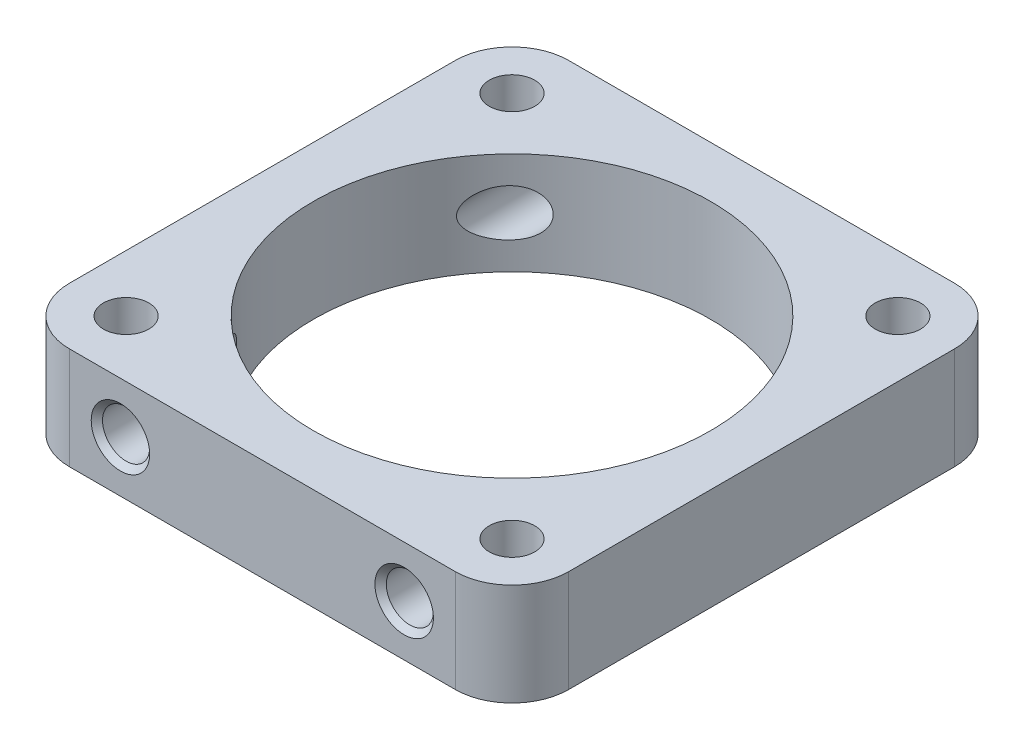
from build123d import *

# Parameters (mm, degrees)
SKETCH1_W           = 88
SKETCH1_H           = 88
BOSS_EXTRUDE1_DEPTH = 18
FILLET1_R           = 10
SKETCH2_R           = 2.15
CUT_EXTRUDE1_DEPTH  = 19
SKETCH3_R           = 4.15
CUT_EXTRUDE2_DEPTH  = 89
SKETCH4_R           = 35
CUT_EXTRUDE3_DEPTH  = 19
CHAMFER1_SIZE       = 1
SKETCH5_R           = 4
CUT_EXTRUDE4_DEPTH  = 13


with BuildPart() as part:
    # Sketch1 → Boss-Extrude1 (new body)
    with BuildSketch(Plane(origin=(0, 0, 0), x_dir=(1, 0, 0), z_dir=(0, 1, 0))):
        Rectangle(SKETCH1_W, SKETCH1_H)
    extrude(amount=BOSS_EXTRUDE1_DEPTH)

    # Fillet1
    fillet1_edges = [part.edges().sort_by_distance(p)[0] for p in [
        (-44, 9, -44),
        (-44, 9, 44),
        (44, 9, 44),
        (44, 9, -44),
    ]]
    fillet(fillet1_edges, radius=FILLET1_R)

    # Sketch2 → Cut-Extrude1 (cut, through all)
    with BuildSketch(Plane(origin=(0, 18, 0), x_dir=(1, 0, 0), z_dir=(0, 1, 0))):
        with Locations((-34, 34)):
            Circle(SKETCH2_R)
        with Locations((34, 34)):
            Circle(SKETCH2_R)
        with Locations((34, -34)):
            Circle(SKETCH2_R)
        with Locations((-34, -34)):
            Circle(SKETCH2_R)
    extrude(amount=-CUT_EXTRUDE1_DEPTH, mode=Mode.SUBTRACT)

    # Sketch3 → Cut-Extrude2 (cut, through all)
    with BuildSketch(Plane.XY.offset(44)):
        with Locations((-25, 9)):
            Circle(SKETCH3_R)
        with Locations((25, 9)):
            Circle(SKETCH3_R)
    extrude(amount=-CUT_EXTRUDE2_DEPTH, mode=Mode.SUBTRACT)

    # Sketch4 → Cut-Extrude3 (cut, through all)
    with BuildSketch(Plane(origin=(0, 18, 0), x_dir=(1, 0, 0), z_dir=(0, 1, 0))):
        Circle(SKETCH4_R)
    extrude(amount=-CUT_EXTRUDE3_DEPTH, mode=Mode.SUBTRACT)

    # Chamfer1
    chamfer1_edges = [part.edges().sort_by_distance(p)[0] for p in [
        (-29.15, 9, -44),
        (-29.15, 9, 44),
        (20.85, 9, -44),
        (20.85, 9, 44),
    ]]
    chamfer(chamfer1_edges, length=CHAMFER1_SIZE)

    # Sketch5 → Cut-Extrude4 (cut)
    with BuildSketch(Plane(origin=(0, 18, 0), x_dir=(1, 0, 0), z_dir=(0, 1, 0))):
        with Locations((-34, 34)):
            Circle(SKETCH5_R)
        with Locations((34, 34)):
            Circle(SKETCH5_R)
        with Locations((34, -34)):
            Circle(SKETCH5_R)
        with Locations((-34, -34)):
            Circle(SKETCH5_R)
    extrude(amount=-CUT_EXTRUDE4_DEPTH, mode=Mode.SUBTRACT)


solid = part.part
